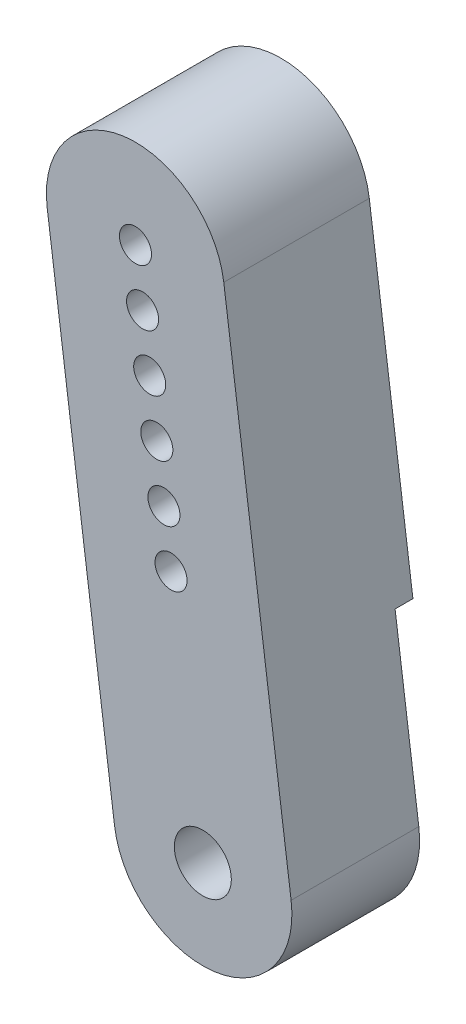
from build123d import *

# Parameters (mm, degrees)
BOSS_EXTRUDE1_START = 2.9
BOSS_EXTRUDE1_DEPTH = 7.167067
BOSS_EXTRUDE2_DEPTH = 1
CUT_EXTRUDE1_REACH  = 10.167
SKETCH3_R           = 0.9
CUT_EXTRUDE2_REACH  = 9.167
SKETCH4_R           = 1.6


with BuildPart() as part:
    # Sketch1 → Boss-Extrude1 (new body)
    with BuildSketch(Plane.XY.offset(BOSS_EXTRUDE1_START)):
        with BuildLine():
            Line((-4.955510048, -0.665522472), (-8.73567769, 27.481774602))
            ThreePointArc((-8.73567769, 27.481774602), (-4.445690114, 33.102807123), (1.175342406, 28.812819547))
            Line((1.175342406, 28.812819547), (4.955510048, 0.665522472))
            ThreePointArc((4.955510048, 0.665522472), (0.665522472, -4.955510048), (-4.955510048, -0.665522472))
        make_face()
    extrude(amount=BOSS_EXTRUDE1_DEPTH)

    # Sketch2 → Boss-Extrude2 (add)
    with BuildSketch(Plane(origin=(0, 0, 2.9), x_dir=(-1, 0, 0), z_dir=(0, 0, -1))):
        with BuildLine():
            Line((-3.624465104, 10.576542569), (-1.175342406, 28.812819547))
            ThreePointArc((-1.175342406, 28.812819547), (4.445690114, 33.102807123), (8.73567769, 27.481774602))
            Line((8.73567769, 27.481774602), (6.286554993, 9.245497624))
            Line((6.286554993, 9.245497624), (-3.624465104, 10.576542569))
        make_face()
    extrude(amount=BOSS_EXTRUDE2_DEPTH)

    # Sketch3 → Cut-Extrude1 (cut, up to next)
    with BuildSketch(Plane(origin=(0, 0, 1.9), x_dir=(-1, 0, 0), z_dir=(0, 0, -1)), mode=Mode.PRIVATE) as cut_extrude1_sk1:
        with Locations((3.780167642, 28.147297074)):
            Circle(SKETCH3_R)
    cut_extrude1_tool1 = extrude(cut_extrude1_sk1.sketch, amount=-CUT_EXTRUDE1_REACH, mode=Mode.PRIVATE) & part.part
    add(cut_extrude1_tool1.solids().sort_by_distance((-3.780168, 28.147297, 1.9))[0], mode=Mode.SUBTRACT)
    # Sketch3 → Cut-Extrude1 (cut, up to next)
    with BuildSketch(Plane(origin=(0, 0, 1.9), x_dir=(-1, 0, 0), z_dir=(0, 0, -1)), mode=Mode.PRIVATE) as cut_extrude1_sk2:
        with Locations((3.380854159, 25.173991045)):
            Circle(SKETCH3_R)
    cut_extrude1_tool2 = extrude(cut_extrude1_sk2.sketch, amount=-CUT_EXTRUDE1_REACH, mode=Mode.PRIVATE) & part.part
    add(cut_extrude1_tool2.solids().sort_by_distance((-3.380854, 25.173991, 1.9))[0], mode=Mode.SUBTRACT)
    # Sketch3 → Cut-Extrude1 (cut, up to next)
    with BuildSketch(Plane(origin=(0, 0, 1.9), x_dir=(-1, 0, 0), z_dir=(0, 0, -1)), mode=Mode.PRIVATE) as cut_extrude1_sk3:
        with Locations((2.981540675, 22.200685016)):
            Circle(SKETCH3_R)
    cut_extrude1_tool3 = extrude(cut_extrude1_sk3.sketch, amount=-CUT_EXTRUDE1_REACH, mode=Mode.PRIVATE) & part.part
    add(cut_extrude1_tool3.solids().sort_by_distance((-2.981541, 22.200685, 1.9))[0], mode=Mode.SUBTRACT)
    # Sketch3 → Cut-Extrude1 (cut, up to next)
    with BuildSketch(Plane(origin=(0, 0, 1.9), x_dir=(-1, 0, 0), z_dir=(0, 0, -1)), mode=Mode.PRIVATE) as cut_extrude1_sk4:
        with Locations((2.582227192, 19.227378987)):
            Circle(SKETCH3_R)
    cut_extrude1_tool4 = extrude(cut_extrude1_sk4.sketch, amount=-CUT_EXTRUDE1_REACH, mode=Mode.PRIVATE) & part.part
    add(cut_extrude1_tool4.solids().sort_by_distance((-2.582227, 19.227379, 1.9))[0], mode=Mode.SUBTRACT)
    # Sketch3 → Cut-Extrude1 (cut, up to next)
    with BuildSketch(Plane(origin=(0, 0, 1.9), x_dir=(-1, 0, 0), z_dir=(0, 0, -1)), mode=Mode.PRIVATE) as cut_extrude1_sk5:
        with Locations((2.182913709, 16.254072958)):
            Circle(SKETCH3_R)
    cut_extrude1_tool5 = extrude(cut_extrude1_sk5.sketch, amount=-CUT_EXTRUDE1_REACH, mode=Mode.PRIVATE) & part.part
    add(cut_extrude1_tool5.solids().sort_by_distance((-2.182914, 16.254073, 1.9))[0], mode=Mode.SUBTRACT)
    # Sketch3 → Cut-Extrude1 (cut, up to next)
    with BuildSketch(Plane(origin=(0, 0, 1.9), x_dir=(-1, 0, 0), z_dir=(0, 0, -1)), mode=Mode.PRIVATE) as cut_extrude1_sk6:
        with Locations((1.783600226, 13.280766929)):
            Circle(SKETCH3_R)
    cut_extrude1_tool6 = extrude(cut_extrude1_sk6.sketch, amount=-CUT_EXTRUDE1_REACH, mode=Mode.PRIVATE) & part.part
    add(cut_extrude1_tool6.solids().sort_by_distance((-1.7836, 13.280767, 1.9))[0], mode=Mode.SUBTRACT)

    # Sketch4 → Cut-Extrude2 (cut, up to next)
    with BuildSketch(Plane(origin=(0, 0, 2.9), x_dir=(-1, 0, 0), z_dir=(0, 0, -1)), mode=Mode.PRIVATE) as cut_extrude2_sk1:
        Circle(SKETCH4_R)
    cut_extrude2_tool1 = extrude(cut_extrude2_sk1.sketch, amount=-CUT_EXTRUDE2_REACH, mode=Mode.PRIVATE) & part.part
    add(cut_extrude2_tool1.solids().sort_by_distance((0, 0, 2.9))[0], mode=Mode.SUBTRACT)


solid = part.part
